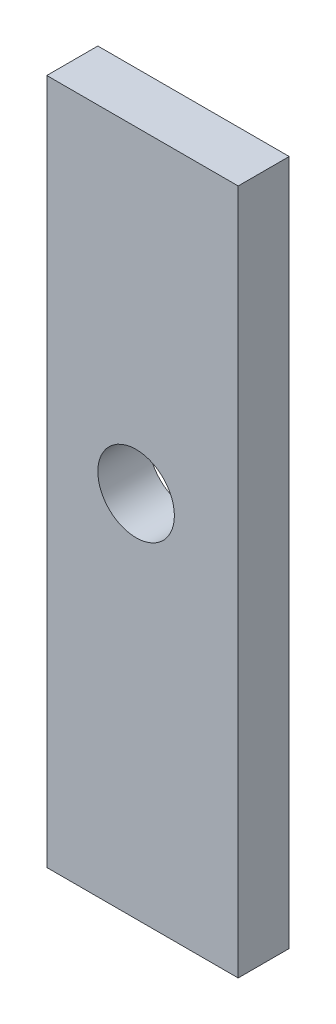
from build123d import *

# Parameters (mm, degrees)
SKETCH1_W           = 7.5
SKETCH1_H           = 26.881
SKETCH1_R           = 1.5
BOSS_EXTRUDE1_DEPTH = 2


with BuildPart() as part:
    # Sketch1 → Boss-Extrude1 (new body)
    with BuildSketch(Plane.XY):
        with Locations((0.25, -1.0005)):
            Rectangle(SKETCH1_W, SKETCH1_H)
        Circle(SKETCH1_R, mode=Mode.SUBTRACT)
    extrude(amount=BOSS_EXTRUDE1_DEPTH)


solid = part.part
